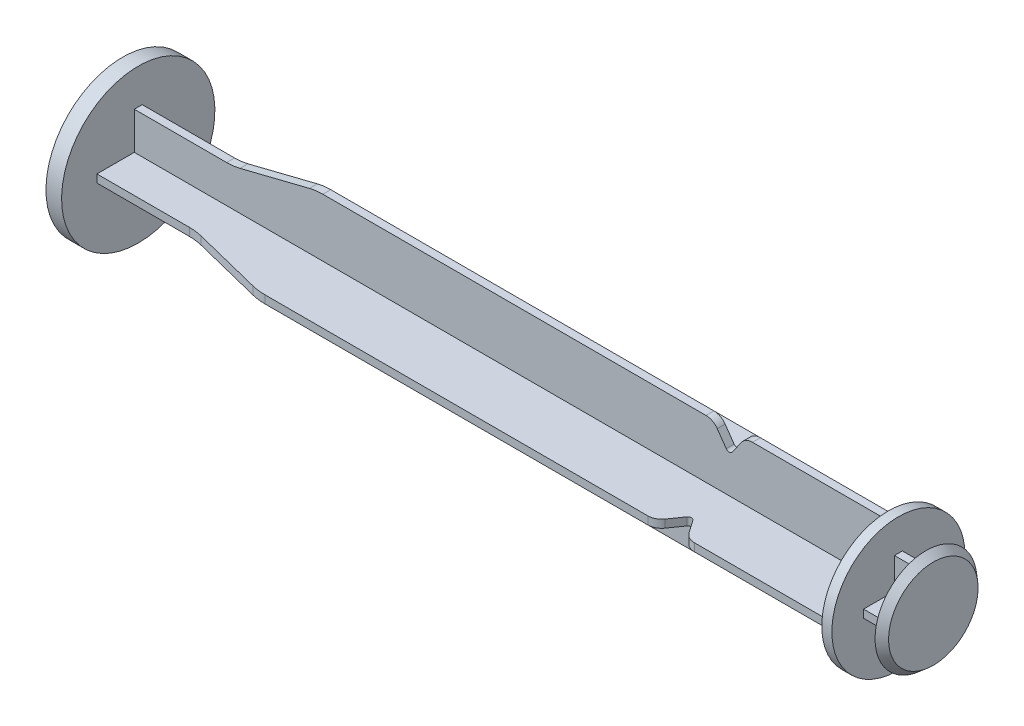
from build123d import *

# Parameters (mm, degrees)
BOSS_EXTRUDE1_DEPTH = 0.43
SKETCH2_R           = 8.35
BOSS_EXTRUDE2_DEPTH = 1.7
CIRPATTERN1_COUNT   = 4
SKETCH3_R           = 7.25
BOSS_EXTRUDE3_DEPTH = 1.1
BOSS_EXTRUDE4_DEPTH = 3
FILLET1_R           = 0.4
FILLET2_R           = 1.5
FILLET3_R           = 6


with BuildPart() as part:
    # Sketch1 → Boss-Extrude1 (new, symmetric)
    with BuildSketch(Plane.XY):
        Polygon((0, 0), (84.5, 0), (84.5, 6.75), (68.25, 6.75), (66.5, 4.25), (64.75, 6.75), (21.5, 6.75), (12.5, 4.5), (0, 4.5), align=None)
    boss_extrude1 = extrude(amount=BOSS_EXTRUDE1_DEPTH, both=True)

    # Sketch2 → Boss-Extrude2 (add)
    with BuildSketch(Plane.ZY):
        Circle(SKETCH2_R)
    extrude(amount=-BOSS_EXTRUDE2_DEPTH)

    # CirPattern1: Boss-Extrude1 ×4 about axis
    cirpattern1_axis = Axis((1.7, 0, 0), (1, 0, 0))
    for i in range(1, CIRPATTERN1_COUNT):
        add(boss_extrude1.rotate(cirpattern1_axis, i * 360 / CIRPATTERN1_COUNT))

    # Sketch3 → Boss-Extrude3 (add)
    with BuildSketch(Plane(origin=(84.5, 0, 0), x_dir=(0, 0, -1), z_dir=(1, 0, 0))):
        Circle(SKETCH3_R)
    extrude(amount=-BOSS_EXTRUDE3_DEPTH)

    # Sketch4 → Boss-Extrude4 (add)
    with BuildSketch(Plane(origin=(84.5, 0, 0), x_dir=(0, 0, -1), z_dir=(1, 0, 0))):
        Polygon((-3.8, -0.43), (-3.8, 0.43), (-0.43, 0.43), (-0.43, 3.8), (0.43, 3.8), (0.43, 0.43), (3.8, 0.43), (3.8, -0.43), (0.43, -0.43), (0.43, -3.8), (-0.43, -3.8), (-0.43, -0.43), align=None)
    extrude(amount=BOSS_EXTRUDE4_DEPTH)

    # Sketch6 → Revolve1 (revolve)
    with BuildSketch(Plane(origin=(0, 0, 0), x_dir=(1, 0, 0), z_dir=(0, 1, 0))):
        Polygon((87.5, 0), (88.3, 0), (88.3, -4.875), (87.5, -5.55), align=None)
    revolve(axis=Axis((87.5, 0, 0), (1, 0, 0)))

    # Fillet1
    fillet1_edges = [part.edges().sort_by_distance(p)[0] for p in [
        (66.5, 0, -4.25),
        (66.5, -4.25, 0),
        (66.5, 0, 4.25),
        (66.5, 4.25, 0),
    ]]
    fillet(fillet1_edges, radius=FILLET1_R)

    # Fillet2
    fillet2_edges = [part.edges().sort_by_distance(p)[0] for p in [
        (68.25, 0, -6.75),
        (64.75, 0, -6.75),
        (68.25, 6.75, 0),
        (64.75, 6.75, 0),
        (64.75, 0, 6.75),
        (68.25, 0, 6.75),
        (64.75, -6.75, 0),
        (68.25, -6.75, 0),
    ]]
    fillet(fillet2_edges, radius=FILLET2_R)

    # Fillet3
    fillet3_edges = [part.edges().sort_by_distance(p)[0] for p in [
        (12.5, 4.5, 0),
        (21.5, 6.75, 0),
        (12.5, 0, -4.5),
        (21.5, 0, -6.75),
        (21.5, -6.75, 0),
        (12.5, -4.5, 0),
        (12.5, 0, 4.5),
        (21.5, 0, 6.75),
    ]]
    fillet(fillet3_edges, radius=FILLET3_R)


solid = part.part
